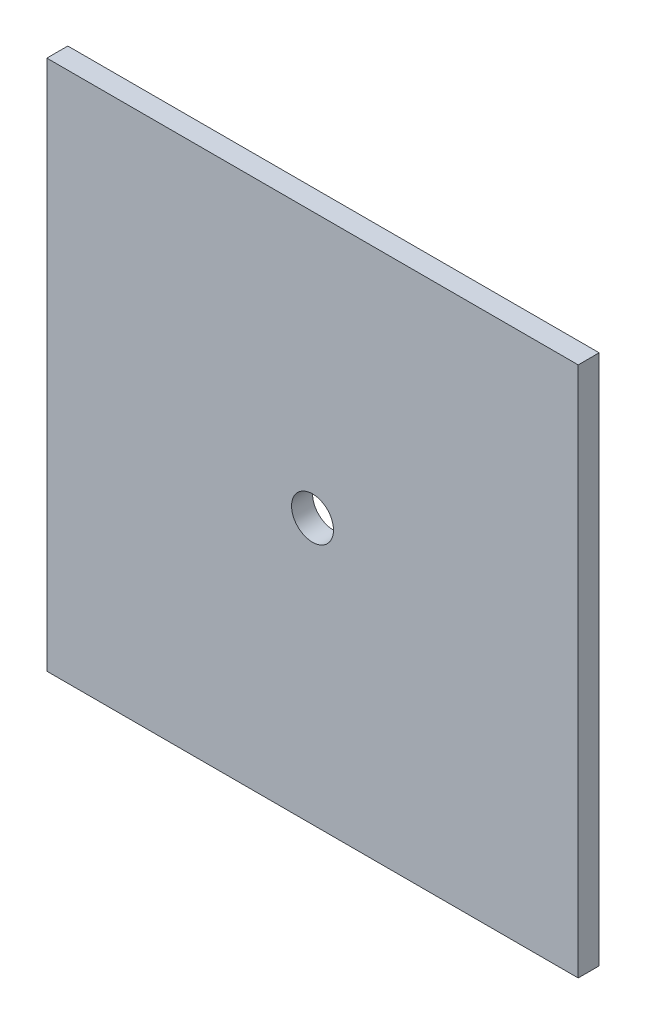
from build123d import *

# Parameters (mm, degrees)
SKETCH1_W           = 76.054070172
SKETCH1_H           = 76
BOSS_EXTRUDE2_DEPTH = 3
SKETCH3_R           = 3
CUT_EXTRUDE1_DEPTH  = 4


with BuildPart() as part:
    # Sketch1 → Boss-Extrude2 (new body)
    with BuildSketch(Plane.XY):
        Rectangle(SKETCH1_W, SKETCH1_H)
    extrude(amount=BOSS_EXTRUDE2_DEPTH)

    # Sketch3 → Cut-Extrude1 (cut, through all)
    with BuildSketch(Plane.XY.offset(3)):
        Circle(SKETCH3_R)
    extrude(amount=-CUT_EXTRUDE1_DEPTH, mode=Mode.SUBTRACT)


solid = part.part
